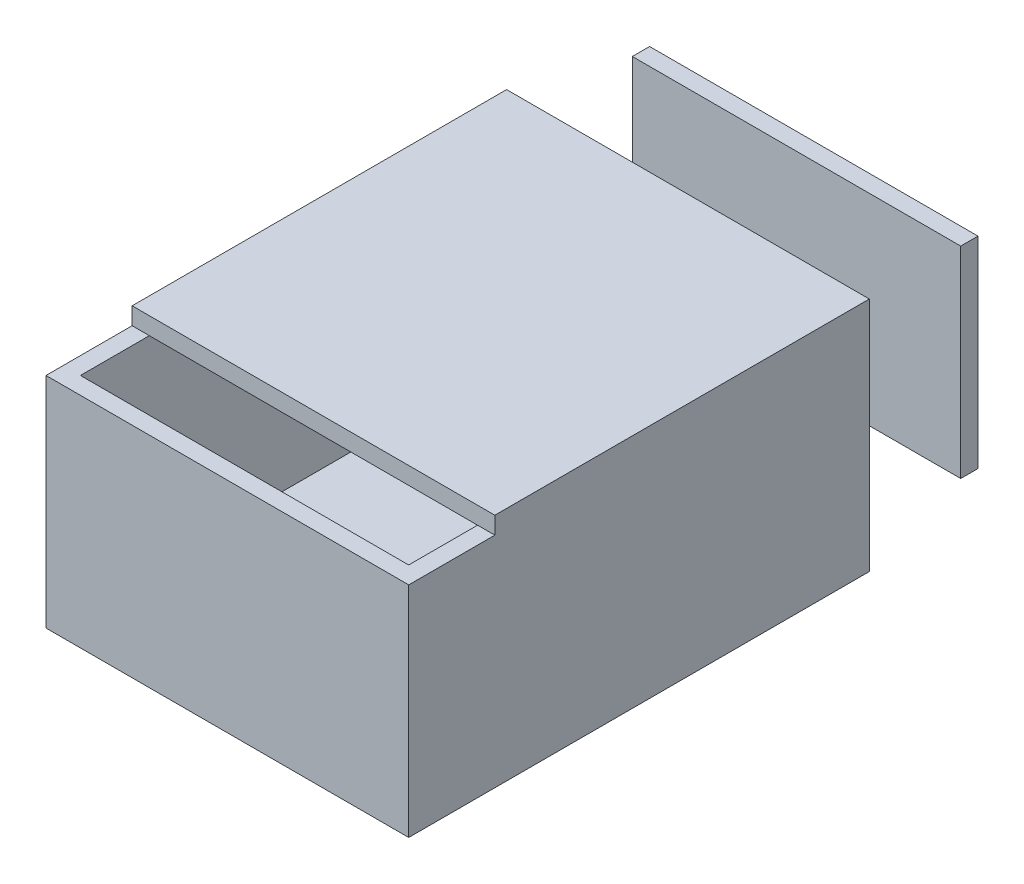
from build123d import *

# Parameters (mm, degrees)
ESBO_O2_W                = 63
ESBO_O2_H                = 80
RESSALTO_EXTRUS_O1_DEPTH = 3
RESSALTO_EXTRUS_O2_DEPTH = 35
ESBO_O4_W                = 63
ESBO_O4_H                = 65.041847247
RESSALTO_EXTRUS_O3_DEPTH = 3
ESBO_O6_W                = 57.038627548
ESBO_O6_H                = 34.967547607
RESSALTO_EXTRUS_O4_DEPTH = 3


with BuildPart() as part:
    # Esboço2 → Ressalto-extrusão1 (new body)
    with BuildSketch(Plane(origin=(0, 0, 0), x_dir=(1, 0, 0), z_dir=(0, 1, 0))):
        with Locations((31.5, -40)):
            Rectangle(ESBO_O2_W, ESBO_O2_H)
    extrude(amount=RESSALTO_EXTRUS_O1_DEPTH)

    # Esboço3 → Ressalto-extrusão2 (add)
    with BuildSketch(Plane(origin=(0, 3, 0), x_dir=(1, 0, 0), z_dir=(0, 1, 0))):
        Polygon((63, -80), (63, 0), (60.001706293, 0), (60.001706293, -77.010558462), (2.99035903, -77.010558462), (2.99035903, 0), (0, 0), (0, -80), align=None)
    extrude(amount=RESSALTO_EXTRUS_O2_DEPTH)

    # Esboço4 → Ressalto-extrusão3 (add)
    with BuildSketch(Plane(origin=(0, 38, 0), x_dir=(1, 0, 0), z_dir=(0, 1, 0))):
        with Locations((31.5, -32.520923624)):
            Rectangle(ESBO_O4_W, ESBO_O4_H)
    extrude(amount=RESSALTO_EXTRUS_O3_DEPTH)


with BuildPart() as body_2:
    # Esboço6 → Ressalto-extrusão4 (new body)
    with BuildSketch(Plane(origin=(0, 0, -20), x_dir=(-1, 0, 0), z_dir=(0, 0, -1))):
        with Locations((-30.355722228, 19.414542594)):
            Rectangle(ESBO_O6_W, ESBO_O6_H)
    extrude(amount=RESSALTO_EXTRUS_O4_DEPTH)


solid = Compound([part.part, body_2.part])
